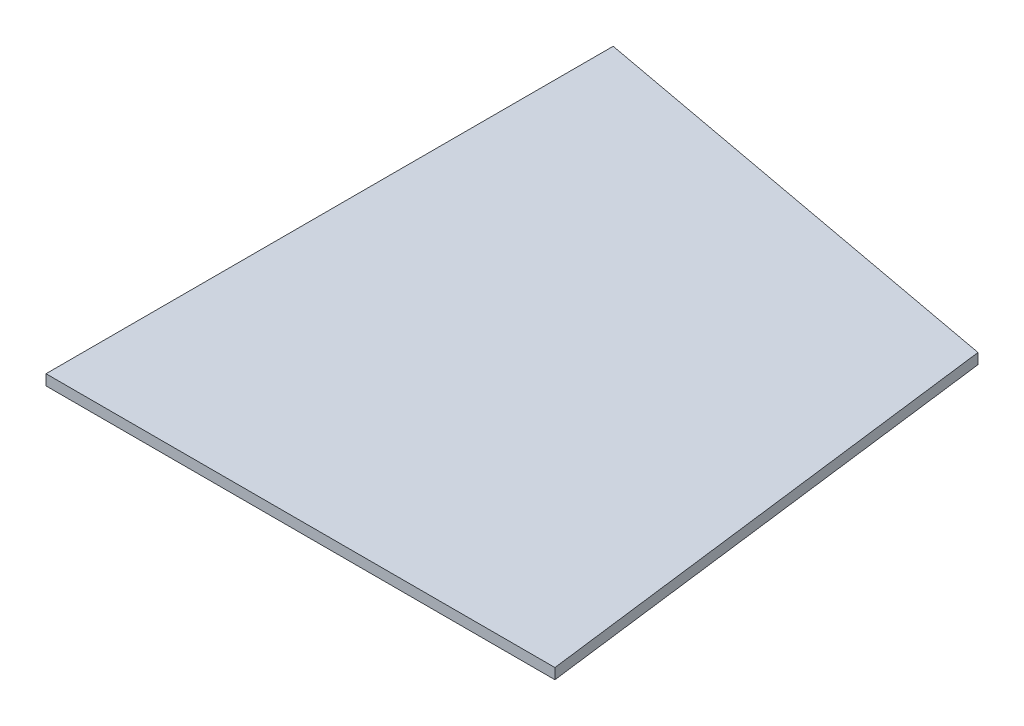
from build123d import *

# Parameters (mm, degrees)
BOSS_EXTRUDE1_DEPTH = 5.4737


with BuildPart() as part:
    # Sketch2 → Boss-Extrude1 (new body)
    with BuildSketch(Plane(origin=(0, 0, 0), x_dir=(1, 0, 0), z_dir=(0, 1, 0))):
        Polygon((0, 0), (0, 293.6875), (231.775, 250.825), (263.525, 0), align=None)
    extrude(amount=BOSS_EXTRUDE1_DEPTH)


solid = part.part
